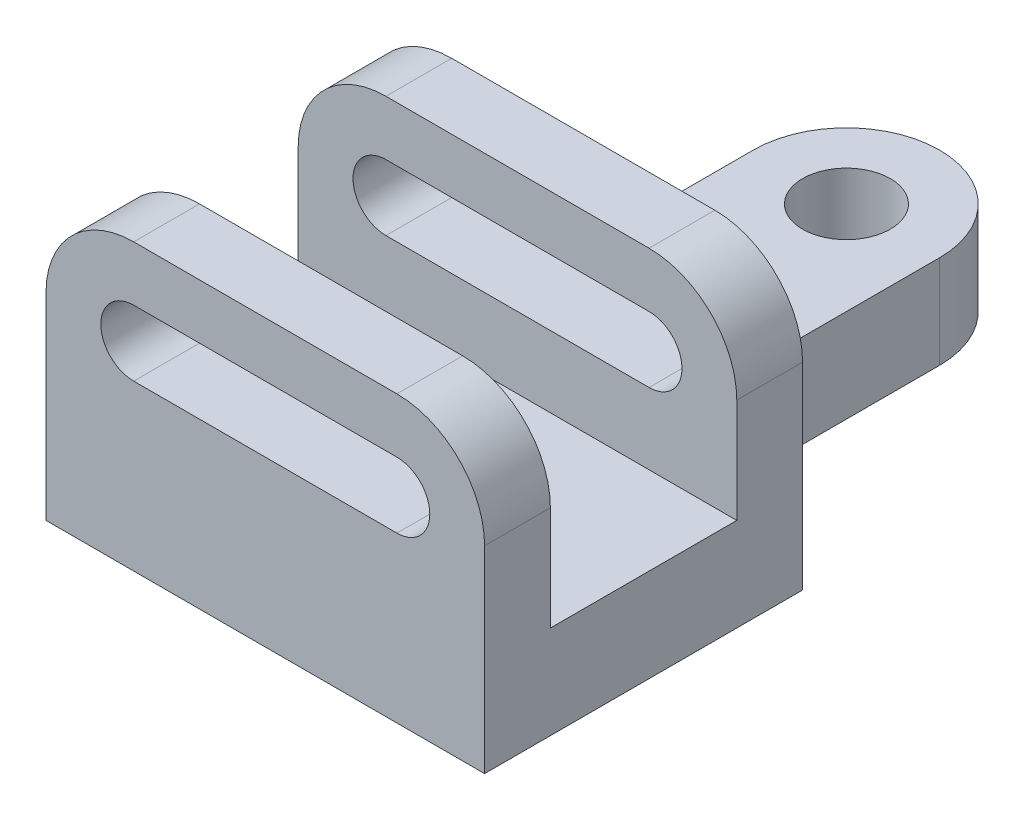
from build123d import *

# Parameters (mm, degrees)
EXTRUDE_2_DEPTH          = 29
SKETCH_3_W               = 34
SKETCH_3_H               = 35
CUT_EXTRUDE_1_DEPTH      = 41
CUT_EXTRUDE_1_DEPTH_BACK = 41
SKETCH_4_R               = 8
EXTRUDE_3_DEPTH          = 17


with BuildPart() as part:
    # 草圖1 → 填料-伸長2 (new body, symmetric)
    with BuildSketch(Plane.XY):
        with BuildLine():
            Line((-24, 16), (24, 16))
            ThreePointArc((24, 16), (35.313708499, 11.313708499), (40, 0))
            Line((40, 0), (40, -36))
            Line((40, -36), (-40, -36))
            Line((-40, -36), (-40, 0))
            ThreePointArc((-40, 0), (-35.313708499, 11.313708499), (-24, 16))
        make_face()
        with BuildLine():
            Line((-24, 6), (24, 6))
            ThreePointArc((24, 6), (30, 0), (24, -6))
            Line((24, -6), (-24, -6))
            ThreePointArc((-24, -6), (-30, 0), (-24, 6))
        make_face(mode=Mode.SUBTRACT)
    extrude(amount=EXTRUDE_2_DEPTH, both=True)

    # 草圖3 → 除料-伸長1 (cut, two sides)
    with BuildSketch(Plane(origin=(0, 0, 0), x_dir=(0, 0, -1), z_dir=(1, 0, 0))) as cut_extrude_1_sk:
        with Locations((0, -1.5)):
            Rectangle(SKETCH_3_W, SKETCH_3_H)
    extrude(amount=CUT_EXTRUDE_1_DEPTH, mode=Mode.SUBTRACT)
    extrude(cut_extrude_1_sk.sketch, amount=-CUT_EXTRUDE_1_DEPTH_BACK, mode=Mode.SUBTRACT)

    # 草圖4 → 填料-伸長3 (add)
    with BuildSketch(Plane.XZ.offset(36)):
        with BuildLine():
            Line((-17, -77), (-17, -45))
            ThreePointArc((-17, -45), (-21.686291501, -33.686291501), (-33, -29))
            Line((-33, -29), (33, -29))
            ThreePointArc((33, -29), (21.686291501, -33.686291501), (17, -45))
            Line((17, -45), (17, -77))
            ThreePointArc((17, -77), (0, -94), (-17, -77))
        make_face()
        with Locations((0, -77)):
            Circle(SKETCH_4_R, mode=Mode.SUBTRACT)
    extrude(amount=-EXTRUDE_3_DEPTH)


solid = part.part
